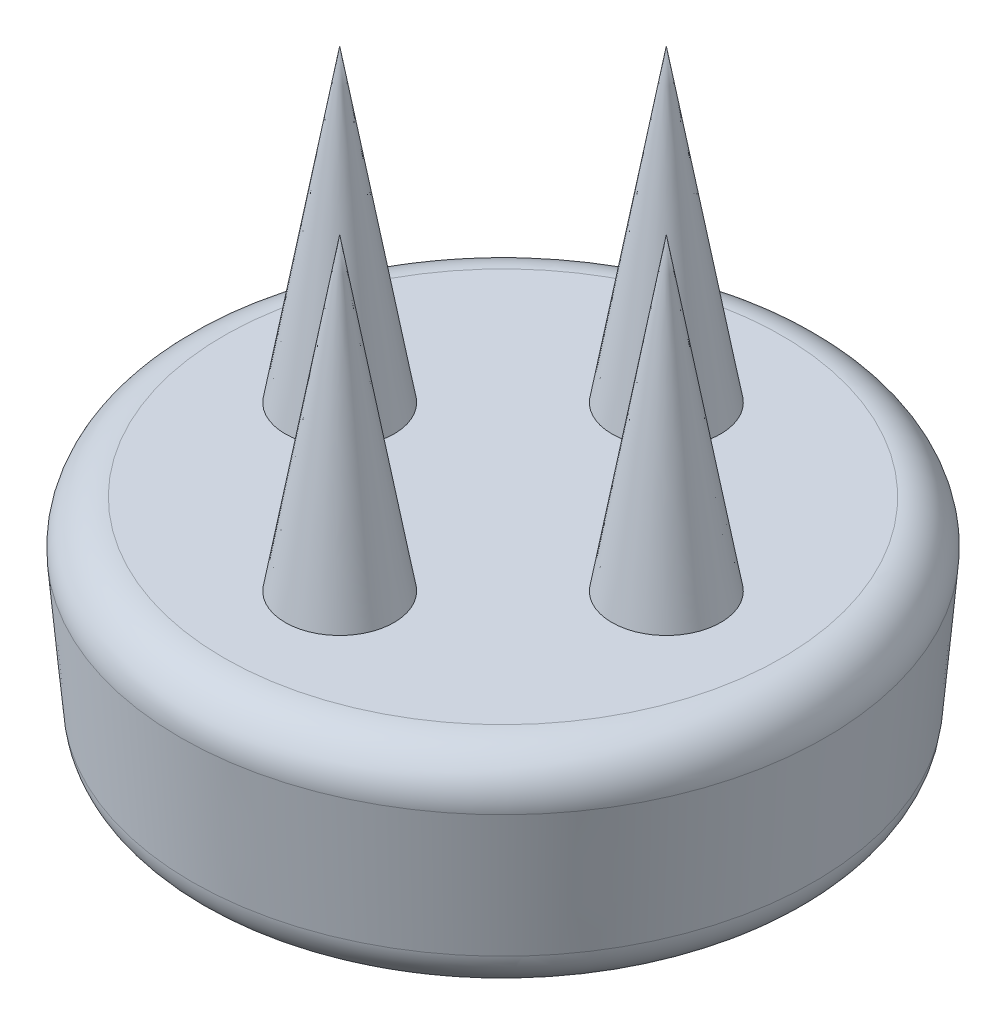
from build123d import *

# Parameters (mm, degrees)
SKETCH1_R           = 15
BOSS_EXTRUDE1_DEPTH = 10
BOSS_EXTRUDE1_DRAFT = -5
SKETCH3_R           = 5
CUT_EXTRUDE1_DEPTH  = 5
FILLET1_R           = 2


with BuildPart() as part:
    # Sketch1 → Boss-Extrude1 (with draft: the straight prism first)
    with BuildSketch(Plane(origin=(0, 0, 0), x_dir=(1, 0, 0), z_dir=(0, 1, 0))):
        Circle(SKETCH1_R)
    extrude(amount=-BOSS_EXTRUDE1_DEPTH)
    # Boss-Extrude1: the draft: its side faces are tilted about the plane it starts from
    boss_extrude1_sides = [part.faces().sort_by_distance(p)[0] for p in [
        (-15, -5, 0),
    ]]
    draft(boss_extrude1_sides, Plane(origin=(0, 0, 0), x_dir=(1, 0, 0), z_dir=(0, 1, 0)), BOSS_EXTRUDE1_DRAFT)

    # Boss-Extrude2 cone 1 section (through the dimple's axis) → Boss-Extrude2 (revolve)
    with BuildSketch(Plane(origin=(0, 0, -7.5), x_dir=(0, 0, -1), z_dir=(1, 0, 0))):
        Polygon((0, 0), (2.5, 0), (0, 14.178204549), align=None)
    revolve(axis=Axis((0, 0, -7.5), (0, 1, 0)))

    # Boss-Extrude2 cone 2 section (through the dimple's axis) → Boss-Extrude2 cone 2 (revolve)
    with BuildSketch(Plane(origin=(7.5, 0, 0), x_dir=(0, 0, -1), z_dir=(1, 0, 0))):
        Polygon((0, 0), (2.5, 0), (0, 14.178204549), align=None)
    revolve(axis=Axis((7.5, 0, 0), (0, 1, 0)))

    # Boss-Extrude2 cone 3 section (through the dimple's axis) → Boss-Extrude2 cone 3 (revolve)
    with BuildSketch(Plane(origin=(0, 0, 7.5), x_dir=(0, 0, -1), z_dir=(1, 0, 0))):
        Polygon((0, 0), (2.5, 0), (0, 14.178204549), align=None)
    revolve(axis=Axis((0, 0, 7.5), (0, 1, 0)))

    # Boss-Extrude2 cone 4 section (through the dimple's axis) → Boss-Extrude2 cone 4 (revolve)
    with BuildSketch(Plane(origin=(-7.5, 0, 0), x_dir=(0, 0, -1), z_dir=(1, 0, 0))):
        Polygon((0, 0), (2.5, 0), (0, 14.178204549), align=None)
    revolve(axis=Axis((-7.5, 0, 0), (0, 1, 0)))

    # Sketch3 → Cut-Extrude1 (cut)
    with BuildSketch(Plane(origin=(0, -10, 0), x_dir=(-1, 0, 0), z_dir=(0, -1, 0))):
        with Locations(Location((0, 0, 0), (0, 0, 90))):
            Circle(SKETCH3_R)
    extrude(amount=-CUT_EXTRUDE1_DEPTH, mode=Mode.SUBTRACT)

    # Fillet1
    fillet1_edges = [part.edges().sort_by_distance(p)[0] for p in [
        (-15, 0, 0),
        (-14.125113365, -10, 0),
    ]]
    fillet(fillet1_edges, radius=FILLET1_R)


solid = part.part
